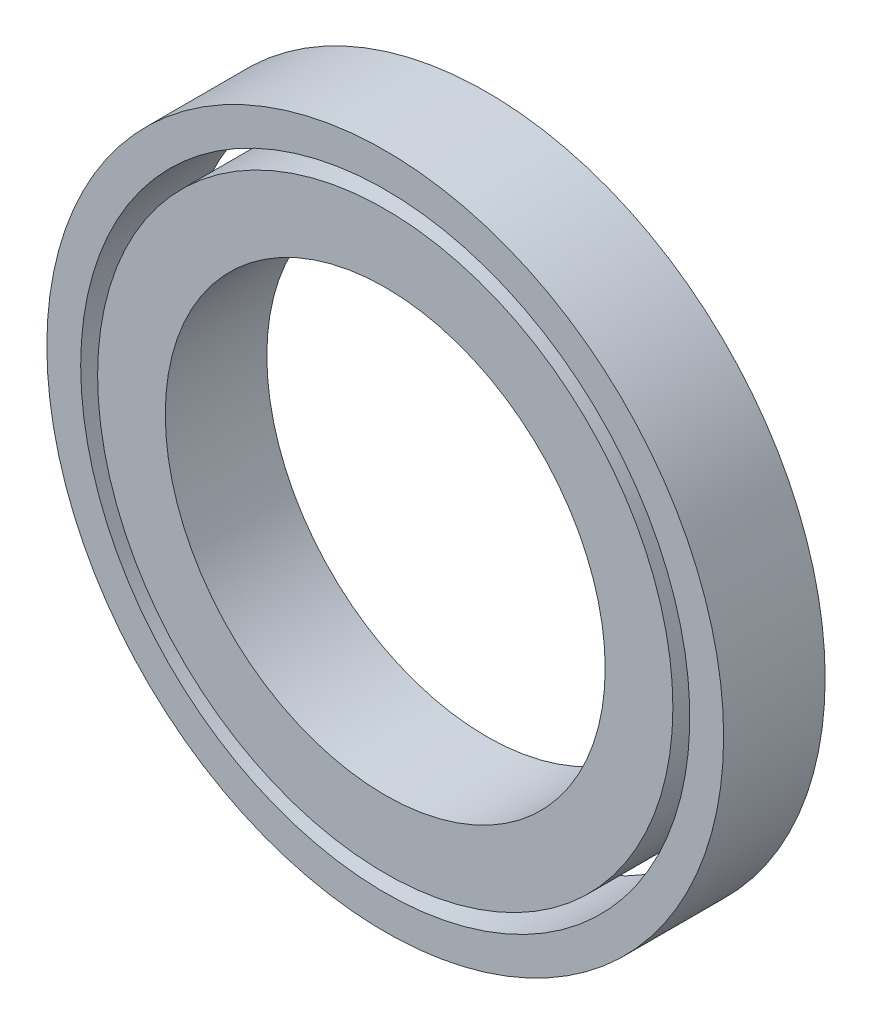
from build123d import *

# Parameters (mm, degrees)
SKETCH1_R           = 17
SKETCH1_R_2         = 13
BOSS_EXTRUDE1_DEPTH = 6
SKETCH2_R           = 20
SKETCH2_R_2         = 18
BOSS_EXTRUDE2_DEPTH = 6


with BuildPart() as part:
    # Sketch1 → Boss-Extrude1 (new body)
    with BuildSketch(Plane.XY):
        Circle(SKETCH1_R)
        Circle(SKETCH1_R_2, mode=Mode.SUBTRACT)
    extrude(amount=BOSS_EXTRUDE1_DEPTH)


with BuildPart() as body_2:
    # Sketch2 → Boss-Extrude2 (new body)
    with BuildSketch(Plane(origin=(0, 0, 0), x_dir=(-1, 0, 0), z_dir=(0, 0, -1))):
        Circle(SKETCH2_R)
        Circle(SKETCH2_R_2, mode=Mode.SUBTRACT)
    extrude(amount=-BOSS_EXTRUDE2_DEPTH)


solid = Compound([part.part, body_2.part])
